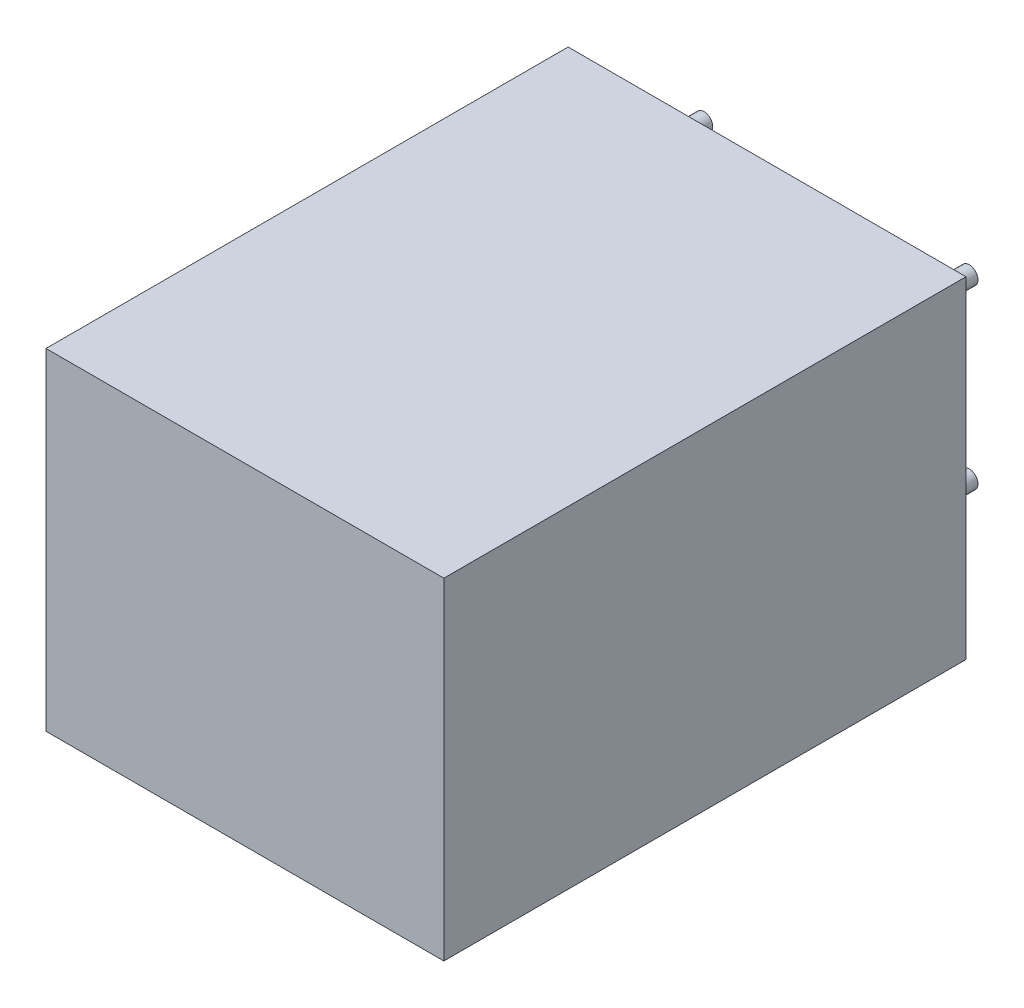
from build123d import *

# Parameters (mm, degrees)
SKETCH1_W               = 11.43
SKETCH1_H               = 9.525
COMPONENT_OUTLINE_DEPTH = 15
SKETCH2_R               = 0.25
EXTRUDE_1_DEPTH         = 2
SKETCH3_R               = 0.25
EXTRUDE_2_DEPTH         = 2
SKETCH4_R               = 0.25
EXTRUDE_3_DEPTH         = 2
SKETCH5_R               = 0.25
EXTRUDE_4_DEPTH         = 2


with BuildPart() as part:
    # Sketch1 → Component_Outline (new body)
    with BuildSketch(Plane.XY):
        with Locations((3.81, 2.2225)):
            Rectangle(SKETCH1_W, SKETCH1_H)
    extrude(amount=COMPONENT_OUTLINE_DEPTH)


with BuildPart() as body_2:
    # Sketch2 → Extrude 1 (new body)
    with BuildSketch(Plane.XY):
        Circle(SKETCH2_R)
    extrude(amount=-EXTRUDE_1_DEPTH)


with BuildPart() as body_3:
    # Sketch3 → Extrude 2 (new body)
    with BuildSketch(Plane.XY):
        with Locations((0, 5.08)):
            Circle(SKETCH3_R)
    extrude(amount=-EXTRUDE_2_DEPTH)


with BuildPart() as body_4:
    # Sketch4 → Extrude 3 (new body)
    with BuildSketch(Plane.XY):
        with Locations((7.62, 5.08)):
            Circle(SKETCH4_R)
    extrude(amount=-EXTRUDE_3_DEPTH)


with BuildPart() as body_5:
    # Sketch5 → Extrude 4 (new body)
    with BuildSketch(Plane.XY):
        with Locations((7.62, 0)):
            Circle(SKETCH5_R)
    extrude(amount=-EXTRUDE_4_DEPTH)


solid = Compound([part.part, body_2.part, body_3.part, body_4.part, body_5.part])
